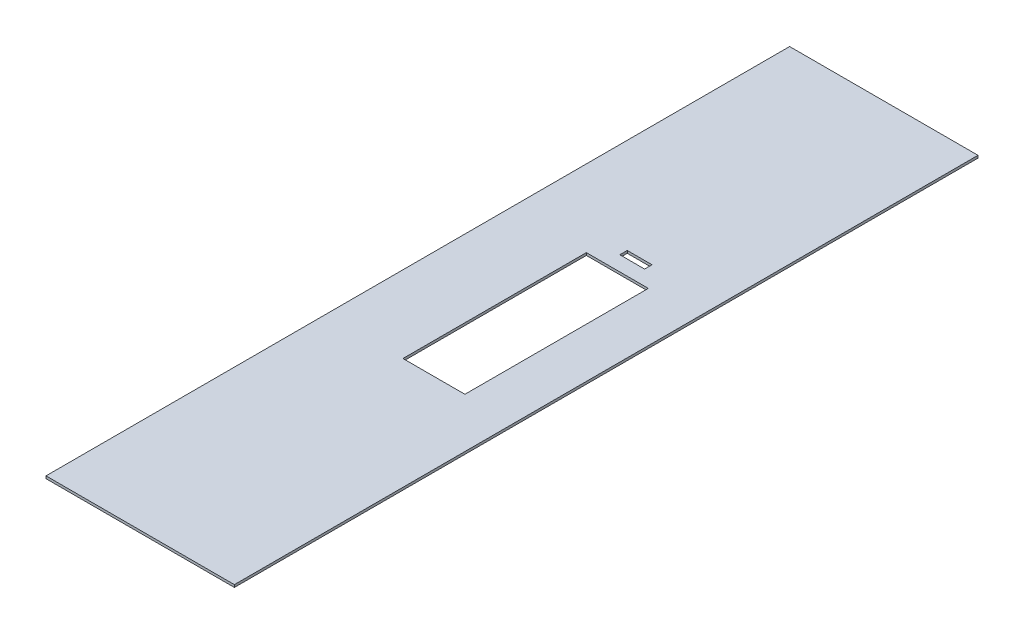
from build123d import *

# Parameters (mm, degrees)
SKIZZE1_W                       = 76
SKIZZE1_H                       = 1
LINEAR_AUSTRAGEN_D_NN1_DEPTH    = 300
SKIZZE2_W                       = 25
SKIZZE2_H                       = 74
SKIZZE2_W_2                     = 10
SKIZZE2_H_2                     = 3
SCHNITT_LINEAR_AUSTRAGEN1_DEPTH = 10


with BuildPart() as part:
    # Skizze1 → Linear-Austragen-Dünn1 (new body)
    with BuildSketch(Plane.XY):
        with Locations((38, -0.5)):
            Rectangle(SKIZZE1_W, SKIZZE1_H)
    extrude(amount=LINEAR_AUSTRAGEN_D_NN1_DEPTH)

    # Skizze2 → Schnitt-Linear austragen1 (cut)
    with BuildSketch(Plane.XZ.offset(1)):
        with Locations((43.5, 150)):
            Rectangle(SKIZZE2_W, SKIZZE2_H)
        with Locations((43.5, 105.5)):
            Rectangle(SKIZZE2_W_2, SKIZZE2_H_2)
    extrude(amount=-SCHNITT_LINEAR_AUSTRAGEN1_DEPTH, mode=Mode.SUBTRACT)


solid = part.part
